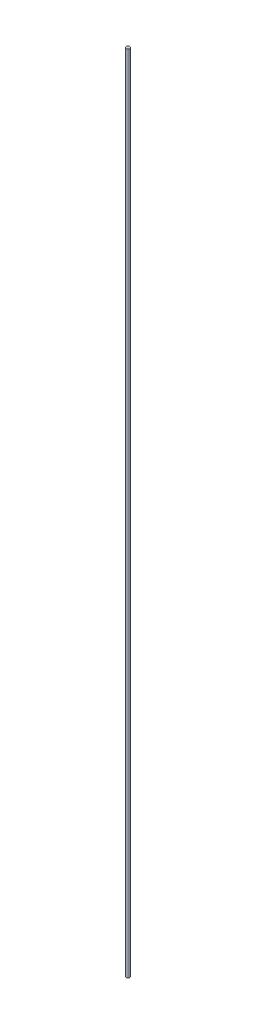
from build123d import *

# Parameters (mm, degrees)
SKETCH1_R           = 0.45
BOSS_EXTRUDE1_DEPTH = 200


with BuildPart() as part:
    # Sketch1 → Boss-Extrude1 (new body)
    with BuildSketch(Plane(origin=(0, 0, 0), x_dir=(1, 0, 0), z_dir=(0, 1, 0))):
        Circle(SKETCH1_R)
    extrude(amount=BOSS_EXTRUDE1_DEPTH)


solid = part.part
